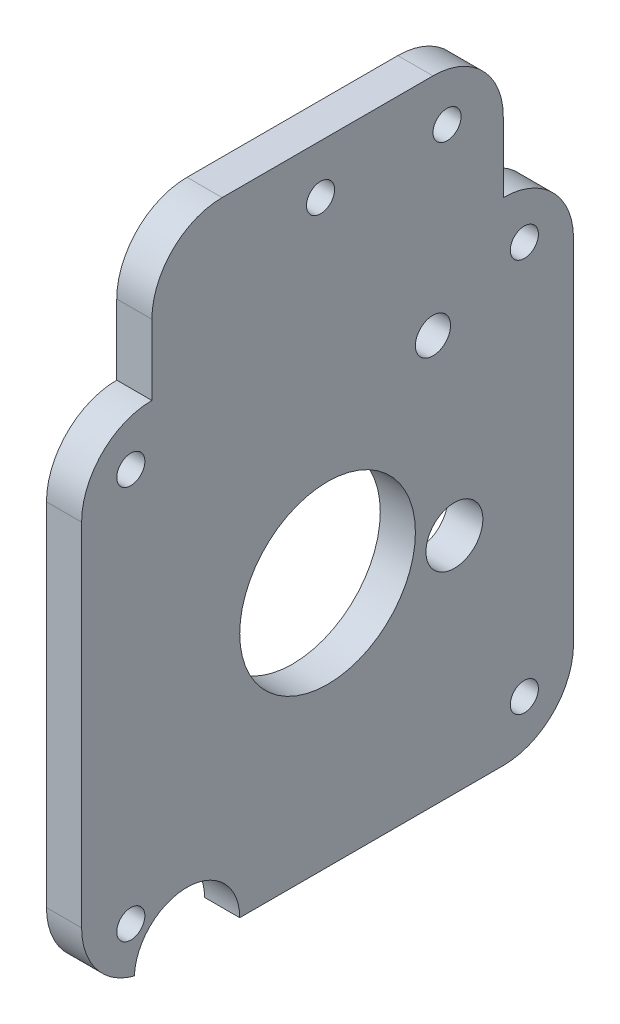
from build123d import *

# Parameters (mm, degrees)
CROQUIS1_R              = 2
CROQUIS1_R_2            = 4.05
CROQUIS1_R_3            = 12.5
SALIENTE_EXTRUIR1_DEPTH = 5
CROQUIS2_R              = 7.5
CROQUIS2_R_2            = 2.5
CROQUIS2_R_3            = 2
CORTAR_EXTRUIR1_DEPTH   = 10


with BuildPart() as part:
    # Croquis1 → Saliente-Extruir1 (new body)
    with BuildSketch(Plane(origin=(0, 0, 0), x_dir=(0, 0, -1), z_dir=(1, 0, 0))):
        with BuildLine():
            Line((10, 0), (60, 0))
            ThreePointArc((60, 0), (67.071067812, 2.928932188), (70, 10))
            Line((70, 10), (70, 60))
            ThreePointArc((70, 60), (67.071067812, 67.071067812), (60, 70))
            Line((60, 70), (60, 80))
            ThreePointArc((60, 80), (57.071067812, 87.071067812), (50, 90))
            Line((50, 90), (20, 90))
            ThreePointArc((20, 90), (12.928932188, 87.071067812), (10, 80))
            Line((10, 80), (10, 70))
            ThreePointArc((10, 70), (2.928932188, 67.071067812), (0, 60))
            Line((0, 60), (0, 10))
            ThreePointArc((0, 10), (2.928932188, 2.928932188), (10, 0))
        make_face()
        with Locations((7, 63)):
            Circle(CROQUIS1_R, mode=Mode.SUBTRACT)
        with Locations((63, 63)):
            Circle(CROQUIS1_R, mode=Mode.SUBTRACT)
        with Locations((63, 7)):
            Circle(CROQUIS1_R, mode=Mode.SUBTRACT)
        with Locations((7, 7)):
            Circle(CROQUIS1_R, mode=Mode.SUBTRACT)
        with Locations((53.05, 31.84)):
            Circle(CROQUIS1_R_2, mode=Mode.SUBTRACT)
        with Locations((35, 35)):
            Circle(CROQUIS1_R_3, mode=Mode.SUBTRACT)
    extrude(amount=SALIENTE_EXTRUIR1_DEPTH)

    # Croquis2 → Cortar-Extruir1 (cut)
    with BuildSketch(Plane(origin=(5, 0, 0), x_dir=(0, 0, -1), z_dir=(1, 0, 0))):
        with Locations((15, 0)):
            Circle(CROQUIS2_R)
        with Locations((50, 58)):
            Circle(CROQUIS2_R_2)
        with Locations((52, 83)):
            Circle(CROQUIS2_R_3)
        with Locations((34, 83)):
            Circle(CROQUIS2_R_3)
    extrude(amount=-CORTAR_EXTRUIR1_DEPTH, mode=Mode.SUBTRACT)


solid = part.part
